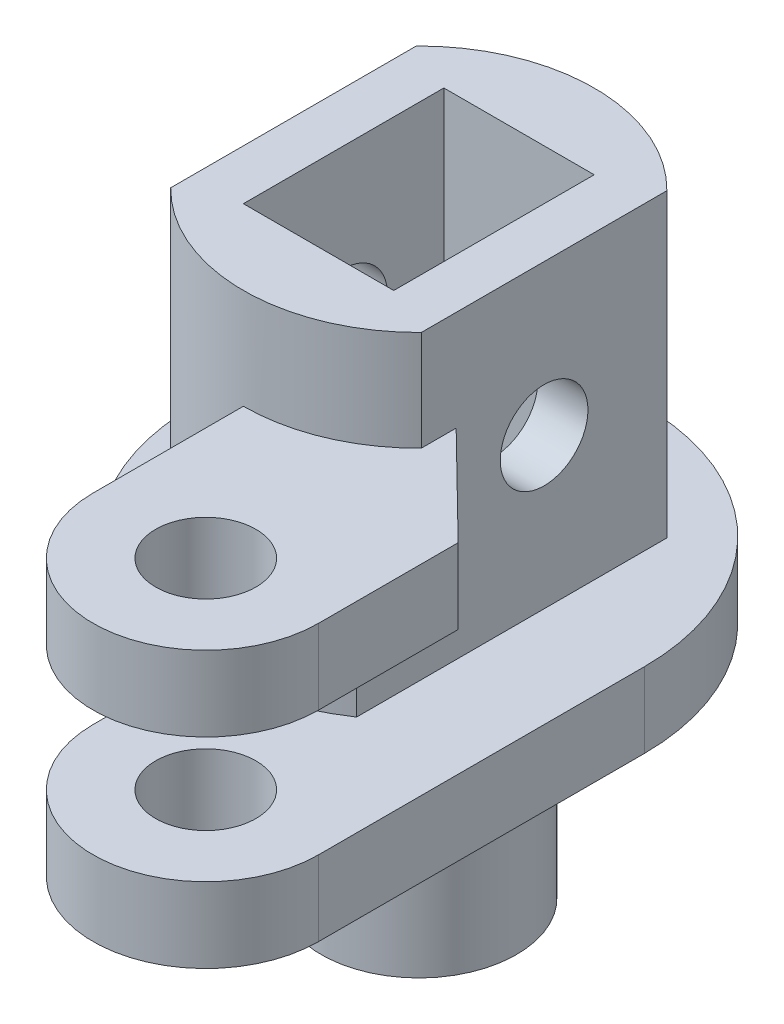
from build123d import *

# Parameters (mm, degrees)
SKETCH1_R               = 9
MAIN_BODY_DEPTH         = 15
SKETCH4_R               = 6.4
BOSS_EXTRUDE3_DEPTH     = 2.5
SKETCH5_R               = 3.9
BOSS_EXTRUDE4_DEPTH     = 7
SKETCH9_R               = 2
ARM_ATTTACH_DEPTH       = 3
SKETCH11_W              = 18
SKETCH11_H              = 12
CUT_EXTRUDE1_DEPTH      = 5
SKETCH13_R              = 2
ARM_ATTACH_DEPTH        = 3
CUT_EXTRUDE5_DEPTH      = 12
SKETCH14_W              = 6
SKETCH14_H              = 8
BLADE_HOLE_DEPTH        = 12
SKETCH21_W              = 15
SKETCH21_H              = 12
FACE_CUT_DEPTH          = 10
SKETCH23_R              = 9
SKETCH23_R_2            = 7
CUT_EXTRUDE8_DEPTH      = 4
SKETCH24_R              = 1.75
SCREW_HOLE_DEPTH        = 15
SKETCH26_R              = 1.65
CUT_EXTRUDE9_DEPTH      = 16
CUT_EXTRUDE9_DEPTH_BACK = 10.5


with BuildPart() as part:
    # Sketch1 → main body (new body)
    with BuildSketch(Plane(origin=(0, 0, 0), x_dir=(1, 0, 0), z_dir=(0, 1, 0))):
        Circle(SKETCH1_R)
    extrude(amount=MAIN_BODY_DEPTH)

    # Sketch4 → Boss-Extrude3 (add)
    with BuildSketch(Plane.XZ):
        Circle(SKETCH4_R)
    extrude(amount=BOSS_EXTRUDE3_DEPTH)

    # Sketch5 → Boss-Extrude4 (add)
    with BuildSketch(Plane.XZ.offset(2.5)):
        Circle(SKETCH5_R)
    extrude(amount=BOSS_EXTRUDE4_DEPTH)

    # Sketch9 → arm atttach (add)
    with BuildSketch(Plane.XZ):
        with BuildLine():
            Line((0, 9), (0, 13))
            ThreePointArc((0, 13), (4.5, 17.5), (9, 13))
            Line((9, 13), (9, 0))
            ThreePointArc((9, 0), (6.363961031, 6.363961031), (0, 9))
        make_face()
        with Locations((4.5, 13)):
            Circle(SKETCH9_R, mode=Mode.SUBTRACT)
    extrude(amount=-ARM_ATTTACH_DEPTH)

    # Sketch11 → Cut-Extrude1 (cut)
    with BuildSketch(Plane(origin=(5, 0, 0), x_dir=(0, 0, -1), z_dir=(1, 0, 0))):
        with Locations((0, 9)):
            Rectangle(SKETCH11_W, SKETCH11_H)
    extrude(amount=CUT_EXTRUDE1_DEPTH, mode=Mode.SUBTRACT)

    # Sketch13 → arm attach (add)
    with BuildSketch(Plane(origin=(0, 8, 0), x_dir=(1, 0, 0), z_dir=(0, 1, 0))):
        with BuildLine():
            Line((0, -13), (0, -9))
            ThreePointArc((0, -9), (2.61248608, -8.61248608), (5, -7.483314774))
            Line((5, -7.483314774), (5, -3.50923953))
            Line((5, -3.50923953), (9, -7.42923953))
            Line((9, -7.42923953), (9, -13))
            ThreePointArc((9, -13), (4.5, -17.5), (0, -13))
        make_face()
        with Locations((4.5, -13)):
            Circle(SKETCH13_R, mode=Mode.SUBTRACT)
    extrude(amount=ARM_ATTACH_DEPTH)

    # Sketch19 → Cut-Extrude5 (cut)
    with BuildSketch(Plane(origin=(0, 15, 0), x_dir=(1, 0, 0), z_dir=(0, 1, 0))):
        with BuildLine():
            Line((0, -7), (0, -9))
            ThreePointArc((0, -9), (-3.939351121, 8.092064801), (7.083885455, -5.551447276))
            Line((7.083885455, -5.551447276), (5.644138479, -4.14049524))
            ThreePointArc((5.644138479, -4.14049524), (-3.163584464, 6.244336101), (0, -7))
        make_face()
    extrude(amount=-CUT_EXTRUDE5_DEPTH, mode=Mode.SUBTRACT)

    # Sketch14 → blade hole (cut)
    with BuildSketch(Plane(origin=(0, 15, 0), x_dir=(1, 0, 0), z_dir=(0, 1, 0))):
        Rectangle(SKETCH14_W, SKETCH14_H)
    extrude(amount=-BLADE_HOLE_DEPTH, mode=Mode.SUBTRACT)

    # Sketch21 → face cut (cut)
    with BuildSketch(Plane.ZY.offset(5)):
        with Locations((0, 9)):
            Rectangle(SKETCH21_W, SKETCH21_H)
    extrude(amount=FACE_CUT_DEPTH, mode=Mode.SUBTRACT)

    # Sketch23 → Cut-Extrude8 (cut)
    with BuildSketch(Plane(origin=(0, 15, 0), x_dir=(1, 0, 0), z_dir=(0, 1, 0))):
        Circle(SKETCH23_R)
        Circle(SKETCH23_R_2, mode=Mode.SUBTRACT)
    extrude(amount=-CUT_EXTRUDE8_DEPTH, mode=Mode.SUBTRACT)

    # Sketch24 → screw hole (cut, symmetric)
    with BuildSketch(Plane.ZY.offset(5)):
        with Locations((0, 9)):
            Circle(SKETCH24_R)
    extrude(amount=SCREW_HOLE_DEPTH, both=True, mode=Mode.SUBTRACT)

    # Sketch26 → Cut-Extrude9 (cut, two sides)
    with BuildSketch(Plane(origin=(0, 0, 0), x_dir=(1, 0, 0), z_dir=(0, 1, 0))) as cut_extrude9_sk:
        Circle(SKETCH26_R)
    extrude(amount=CUT_EXTRUDE9_DEPTH, mode=Mode.SUBTRACT)
    extrude(cut_extrude9_sk.sketch, amount=-CUT_EXTRUDE9_DEPTH_BACK, mode=Mode.SUBTRACT)


solid = part.part
